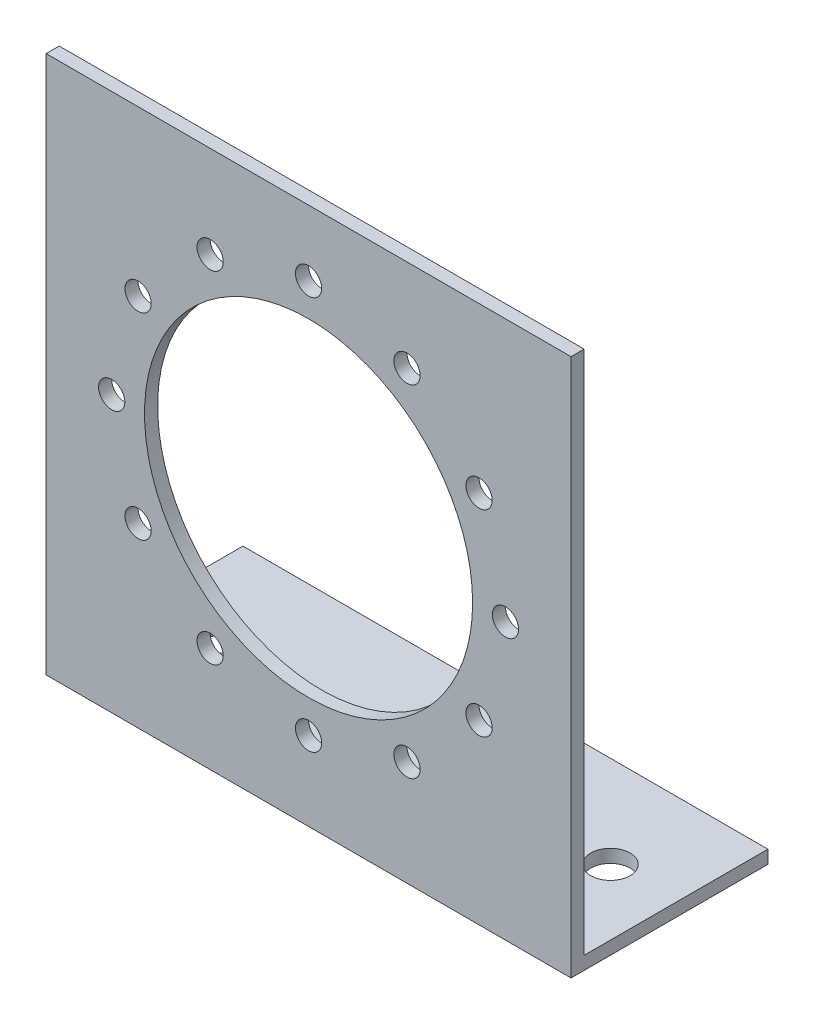
from build123d import *

# Parameters (mm, degrees)
SKETCH1_W           = 40
SKETCH1_H           = 40
SKETCH1_R           = 12.5
SKETCH1_R_2         = 1
BOSS_EXTRUDE2_DEPTH = 1
SKETCH2_W           = 40
SKETCH2_H           = 1
BOSS_EXTRUDE3_DEPTH = 15
SKETCH3_R           = 1.5
CUT_EXTRUDE1_DEPTH  = 2


with BuildPart() as part:
    # Sketch1 → Boss-Extrude2 (new body)
    with BuildSketch(Plane.XY):
        Rectangle(SKETCH1_W, SKETCH1_H)
        Circle(SKETCH1_R, mode=Mode.SUBTRACT)
        with Locations((0, 15)):
            Circle(SKETCH1_R_2, mode=Mode.SUBTRACT)
        with Locations((7.5, 12.990381057)):
            Circle(SKETCH1_R_2, mode=Mode.SUBTRACT)
        with Locations((12.990381057, 7.5)):
            Circle(SKETCH1_R_2, mode=Mode.SUBTRACT)
        with Locations((15, 0)):
            Circle(SKETCH1_R_2, mode=Mode.SUBTRACT)
        with Locations((12.990381057, -7.5)):
            Circle(SKETCH1_R_2, mode=Mode.SUBTRACT)
        with Locations((7.5, -12.990381057)):
            Circle(SKETCH1_R_2, mode=Mode.SUBTRACT)
        with Locations((0, -15)):
            Circle(SKETCH1_R_2, mode=Mode.SUBTRACT)
        with Locations((-7.5, -12.990381057)):
            Circle(SKETCH1_R_2, mode=Mode.SUBTRACT)
        with Locations((-12.990381057, -7.5)):
            Circle(SKETCH1_R_2, mode=Mode.SUBTRACT)
        with Locations((-15, 0)):
            Circle(SKETCH1_R_2, mode=Mode.SUBTRACT)
        with Locations((-12.990381057, 7.5)):
            Circle(SKETCH1_R_2, mode=Mode.SUBTRACT)
        with Locations((-7.5, 12.990381057)):
            Circle(SKETCH1_R_2, mode=Mode.SUBTRACT)
    extrude(amount=BOSS_EXTRUDE2_DEPTH)

    # Sketch2 → Boss-Extrude3 (add)
    with BuildSketch(Plane.XY.offset(1)):
        with Locations((0, -20.5)):
            Rectangle(SKETCH2_W, SKETCH2_H)
    extrude(amount=-BOSS_EXTRUDE3_DEPTH)

    # Sketch3 → Cut-Extrude1 (cut, through all)
    with BuildSketch(Plane(origin=(0, -20, 0), x_dir=(1, 0, 0), z_dir=(0, 1, 0))):
        with Locations((-15, 7)):
            Circle(SKETCH3_R)
        with Locations((15, 7)):
            Circle(SKETCH3_R)
    extrude(amount=-CUT_EXTRUDE1_DEPTH, mode=Mode.SUBTRACT)


solid = part.part
